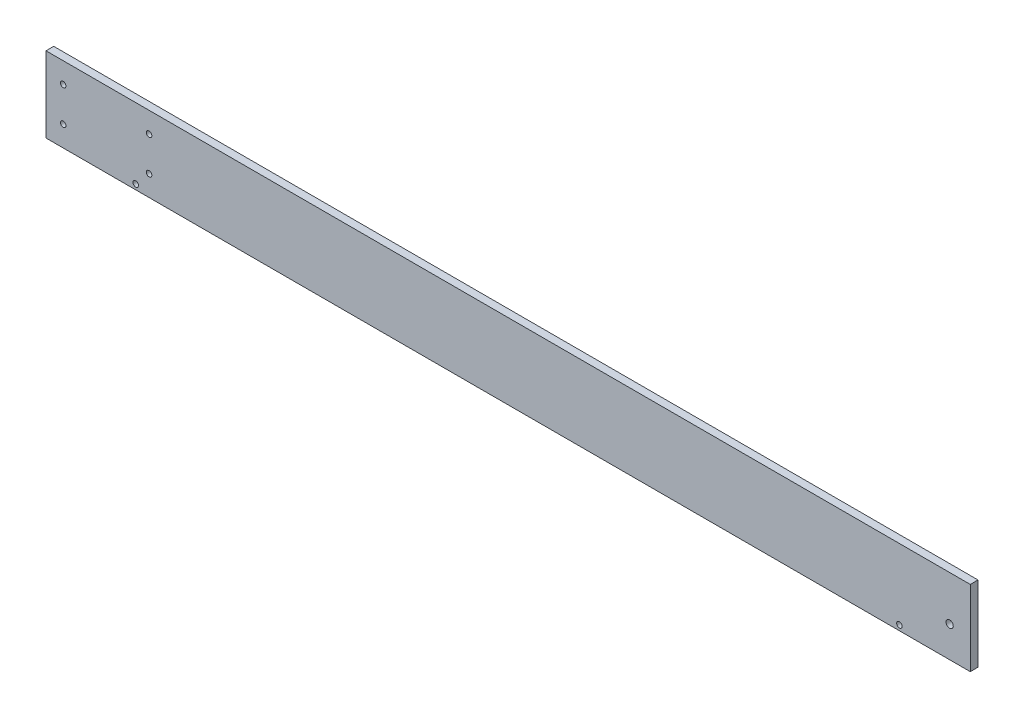
from build123d import *

# Parameters (mm, degrees)
SKETCH1_W           = 538
SKETCH1_H           = 44
SKETCH1_R           = 2.1
SKETCH1_R_2         = 1.6
BOSS_EXTRUDE1_DEPTH = 4.5


with BuildPart() as part:
    # Sketch1 → Boss-Extrude1 (new body)
    with BuildSketch(Plane.XY):
        Rectangle(SKETCH1_W, SKETCH1_H)
        with Locations((257, -4)):
            Circle(SKETCH1_R, mode=Mode.SUBTRACT)
        with Locations((-259, 10)):
            Circle(SKETCH1_R_2, mode=Mode.SUBTRACT)
        with Locations((-209, 10)):
            Circle(SKETCH1_R_2, mode=Mode.SUBTRACT)
        with Locations((-209, -10)):
            Circle(SKETCH1_R_2, mode=Mode.SUBTRACT)
        with Locations((-259, -10)):
            Circle(SKETCH1_R_2, mode=Mode.SUBTRACT)
        with Locations((227.75, -19)):
            Circle(SKETCH1_R_2, mode=Mode.SUBTRACT)
        with Locations((-216.75, -19)):
            Circle(SKETCH1_R_2, mode=Mode.SUBTRACT)
    extrude(amount=BOSS_EXTRUDE1_DEPTH)


solid = part.part
